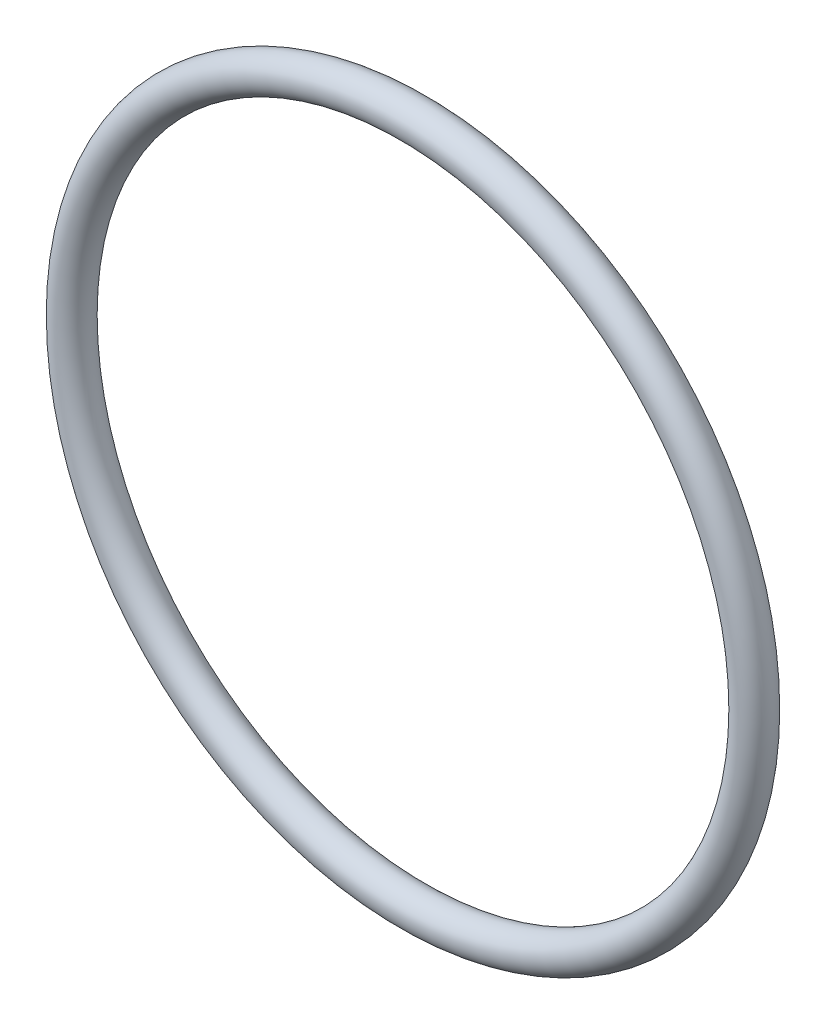
from build123d import *

# Parameters (mm, degrees)
SKETCH4_R = 1.3081


with BuildPart() as part:
    # Sketch4 → Revolve2 (revolve)
    with BuildSketch(Plane(origin=(0, 0, 0), x_dir=(1, 0, 0), z_dir=(0, 1, 0))):
        Circle(SKETCH4_R)
    revolve(axis=Axis((24.81, 0, 1.43891), (0, 0, -1)))


solid = part.part
